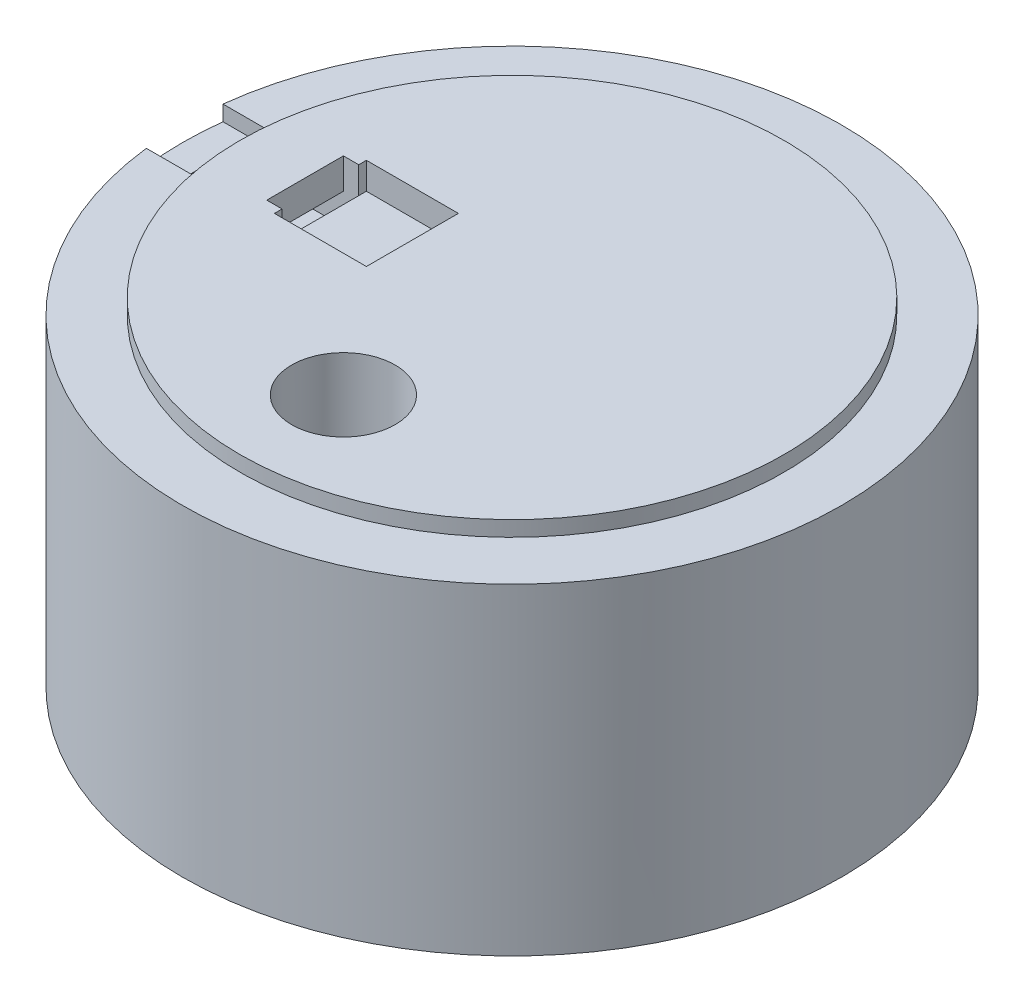
from build123d import *

# Parameters (mm, degrees)
SKETCH2_R           = 43
BOSS_EXTRUDE1_DEPTH = 42
SKETCH3_R           = 35.5
BOSS_EXTRUDE2_DEPTH = 2
CUT_EXTRUDE1_DEPTH  = 30
SKETCH6_W           = 12
SKETCH6_H           = 12
CUT_EXTRUDE2_DEPTH  = 3.5
SKETCH5_W           = 2
SKETCH5_H           = 10
CUT_EXTRUDE3_DEPTH  = 8
SKETCH7_R           = 6.75
CUT_EXTRUDE4_DEPTH  = 14
CUT_EXTRUDE5_DEPTH  = 2
CUT_EXTRUDE6_DEPTH  = 41
SKETCH10_W          = 10
SKETCH10_H          = 4
CUT_EXTRUDE7_DEPTH  = 10
SKETCH11_R          = 8.75
SKETCH11_R_2        = 6.75
BOSS_EXTRUDE3_DEPTH = 2


with BuildPart() as part:
    # Sketch2 → Boss-Extrude1 (new body)
    with BuildSketch(Plane(origin=(0, 0, 0), x_dir=(1, 0, 0), z_dir=(0, 1, 0))):
        Circle(SKETCH2_R)
    extrude(amount=BOSS_EXTRUDE1_DEPTH)

    # Sketch3 → Boss-Extrude2 (add)
    with BuildSketch(Plane(origin=(0, 42, 0), x_dir=(1, 0, 0), z_dir=(0, 1, 0))):
        Circle(SKETCH3_R)
    extrude(amount=BOSS_EXTRUDE2_DEPTH)

    # Sketch4 → Cut-Extrude1 (cut)
    with BuildSketch(Plane.XZ):
        with BuildLine():
            Line((-3.5, 32.813869019), (-3.5, 37.5))
            Line((-3.5, 37.5), (3.5, 37.5))
            Line((3.5, 37.5), (3.5, 32.813869019))
            ThreePointArc((3.5, 32.813869019), (28.578838325, 16.5), (30.167644167, -13.375845596))
            Line((30.167644167, -13.375845596), (34.225952642, -15.718911087))
            Line((34.225952642, -15.718911087), (30.725952642, -21.781088913))
            Line((30.725952642, -21.781088913), (26.667644167, -19.438023423))
            ThreePointArc((26.667644167, -19.438023423), (0, -33), (-26.667644167, -19.438023423))
            Line((-26.667644167, -19.438023423), (-30.725952642, -21.781088913))
            Line((-30.725952642, -21.781088913), (-34.225952642, -15.718911087))
            Line((-34.225952642, -15.718911087), (-30.167644167, -13.375845596))
            ThreePointArc((-30.167644167, -13.375845596), (-28.578838325, 16.5), (-3.5, 32.813869019))
        make_face()
    extrude(amount=-CUT_EXTRUDE1_DEPTH, mode=Mode.SUBTRACT)

    # Sketch6 → Cut-Extrude2 (cut)
    with BuildSketch(Plane(origin=(0, 44, 0), x_dir=(1, 0, 0), z_dir=(0, 1, 0))):
        with Locations((-19, 0)):
            Rectangle(SKETCH6_W, SKETCH6_H)
    extrude(amount=-CUT_EXTRUDE2_DEPTH, mode=Mode.SUBTRACT)

    # Sketch5 → Cut-Extrude3 (cut)
    with BuildSketch(Plane(origin=(0, 44, 0), x_dir=(1, 0, 0), z_dir=(0, 1, 0))):
        with Locations((-26, 0)):
            Rectangle(SKETCH5_W, SKETCH5_H)
    extrude(amount=-CUT_EXTRUDE3_DEPTH, mode=Mode.SUBTRACT)

    # Sketch7 → Cut-Extrude4 (cut)
    with BuildSketch(Plane(origin=(0, 44, 0), x_dir=(1, 0, 0), z_dir=(0, 1, 0))):
        with Locations((0, -22)):
            Circle(SKETCH7_R)
    extrude(amount=-CUT_EXTRUDE4_DEPTH, mode=Mode.SUBTRACT)

    # Sketch8 → Cut-Extrude5 (cut)
    with BuildSketch(Plane(origin=(0, 42, 0), x_dir=(1, 0, 0), z_dir=(0, 1, 0))):
        with BuildLine():
            Line((-42.708313008, 5), (-35.146123542, 5))
            ThreePointArc((-35.146123542, 5), (-35.5, 0), (-35.146123542, -5))
            Line((-35.146123542, -5), (-42.708313008, -5))
            ThreePointArc((-42.708313008, -5), (-43, 0), (-42.708313008, 5))
        make_face()
    extrude(amount=-CUT_EXTRUDE5_DEPTH, mode=Mode.SUBTRACT)

    # Sketch9 → Cut-Extrude6 (cut)
    with BuildSketch(Plane(origin=(0, 40, 0), x_dir=(1, 0, 0), z_dir=(0, 1, 0))):
        with BuildLine():
            Line((-35.146123542, 5), (-38.927218275, 5))
            Line((-38.927218275, 5), (-38.927218275, -5))
            Line((-38.927218275, -5), (-35.146123542, -5))
            ThreePointArc((-35.146123542, -5), (-35.5, 0), (-35.146123542, 5))
        make_face()
    extrude(amount=-CUT_EXTRUDE6_DEPTH, mode=Mode.SUBTRACT)

    # Sketch10 → Cut-Extrude7 (cut)
    with BuildSketch(Plane(origin=(-27, 0, 0), x_dir=(0, 0, -1), z_dir=(1, 0, 0))):
        with Locations((0, 38)):
            Rectangle(SKETCH10_W, SKETCH10_H)
    extrude(amount=-CUT_EXTRUDE7_DEPTH, mode=Mode.SUBTRACT)

    # Sketch11 → Boss-Extrude3 (add)
    with BuildSketch(Plane.XZ.offset(-30)):
        with Locations((0, 22)):
            Circle(SKETCH11_R)
        with Locations((0, 22)):
            Circle(SKETCH11_R_2, mode=Mode.SUBTRACT)
    extrude(amount=BOSS_EXTRUDE3_DEPTH)


solid = part.part
